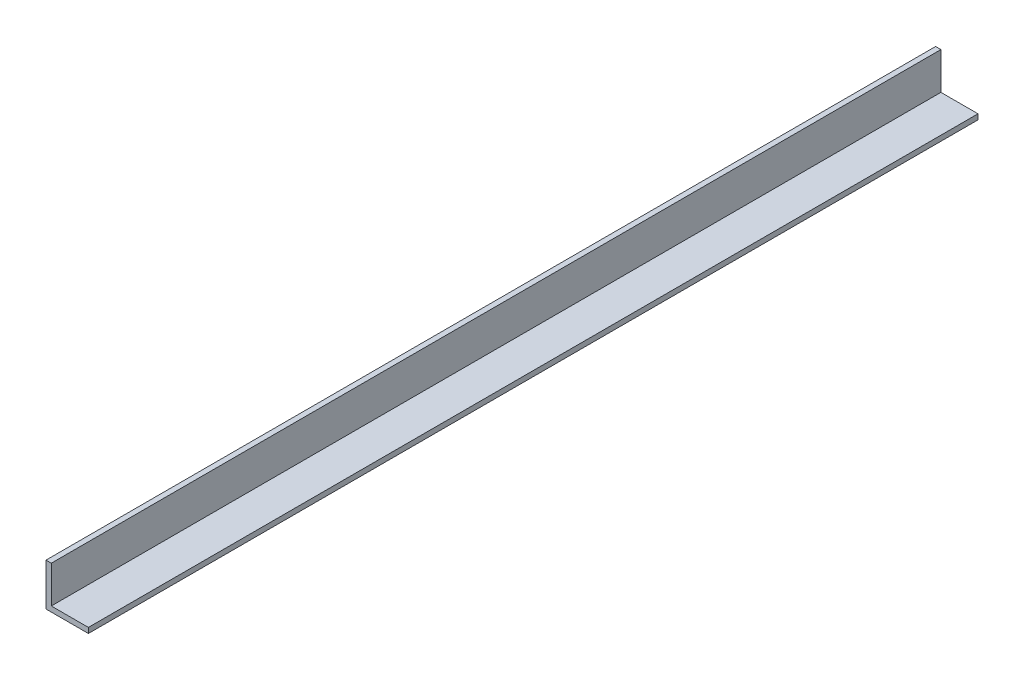
from build123d import *

# Parameters (mm, degrees)
BOSS_EXTRUDE1_DEPTH = 1219.2
FILLET1_R           = 0.4064
SKETCH4_W           = 1905.2
SKETCH4_H           = 103.278519729
CUT_EXTRUDE1_DEPTH  = 60
SKETCH5_W           = 2.47699065
SKETCH5_H           = 2.94685794
CUT_EXTRUDE2_DEPTH  = 600


with BuildPart() as part:
    # Sketch3 → Boss-Extrude1 (new, symmetric)
    with BuildSketch(Plane.XY):
        Polygon((3.175, 25.4), (0, 25.4), (0, 0), (25.4, 0), (25.4, 3.175), (3.175, 3.175), align=None)
    extrude(amount=BOSS_EXTRUDE1_DEPTH, both=True)

    # Fillet1
    fillet1_edges = [part.edges().sort_by_distance(p)[0] for p in [
        (3.175, 3.175, 0),
    ]]
    fillet(fillet1_edges, radius=FILLET1_R)

    # Sketch4 → Cut-Extrude1 (cut)
    with BuildSketch(Plane.ZY):
        with Locations((-266.6, -26.239259864)):
            Rectangle(SKETCH4_W, SKETCH4_H)
    extrude(amount=-CUT_EXTRUDE1_DEPTH, mode=Mode.SUBTRACT)

    # Sketch5 → Cut-Extrude2 (cut)
    with BuildSketch(Plane(origin=(0, 0, 686), x_dir=(-1, 0, 0), z_dir=(0, 0, -1))):
        with Locations((-4.413495325, 4.64842897)):
            Rectangle(SKETCH5_W, SKETCH5_H)
    extrude(amount=-CUT_EXTRUDE2_DEPTH, mode=Mode.SUBTRACT)


solid = part.part
